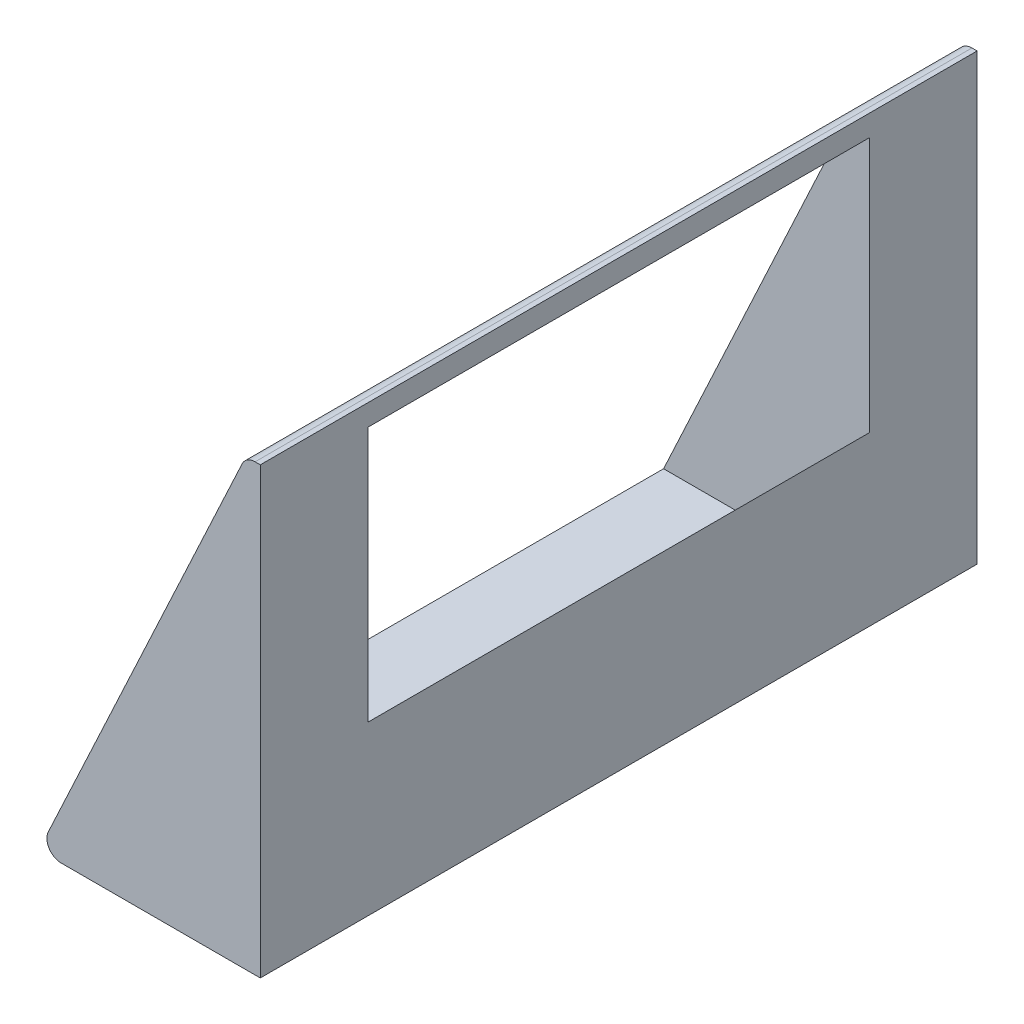
from build123d import *

# Parameters (mm, degrees)
BOSS_EXTRUDE1_DEPTH = 500
SKETCH2_W           = 350
SKETCH2_H           = 300
CUT_EXTRUDE1_DEPTH  = 100


with BuildPart() as part:
    # Sketch1 → Boss-Extrude1 (new body)
    with BuildSketch(Plane.XY):
        with BuildLine():
            Line((0, 0), (0, 310))
            Line((0, 310), (-3.629297392, 310))
            ThreePointArc((-3.629297392, 310), (-9.002293475, 308.433914458), (-12.692375262, 304.226182617))
            Line((-12.692375262, 304.226182617), (-147.921596127, 14.226182617))
            ThreePointArc((-147.921596127, 14.226182617), (-147.292432715, 4.627003917), (-138.858518257, 0))
            Line((-138.858518257, 0), (0, 0))
        make_face()
    extrude(amount=BOSS_EXTRUDE1_DEPTH)

    # Sketch2 → Cut-Extrude1 (cut, along a direction that is not the sketch's normal)
    with BuildSketch(Plane(origin=(-126.950826732, 59.198142714, 0), x_dir=(0, 0, 1), z_dir=(-0.906307787, 0.422618262, 0))):
        with Locations((250, 110.368730506)):
            Rectangle(SKETCH2_W, SKETCH2_H)
    extrude(amount=-CUT_EXTRUDE1_DEPTH, dir=(-1, 0, 0), mode=Mode.SUBTRACT)


solid = part.part
